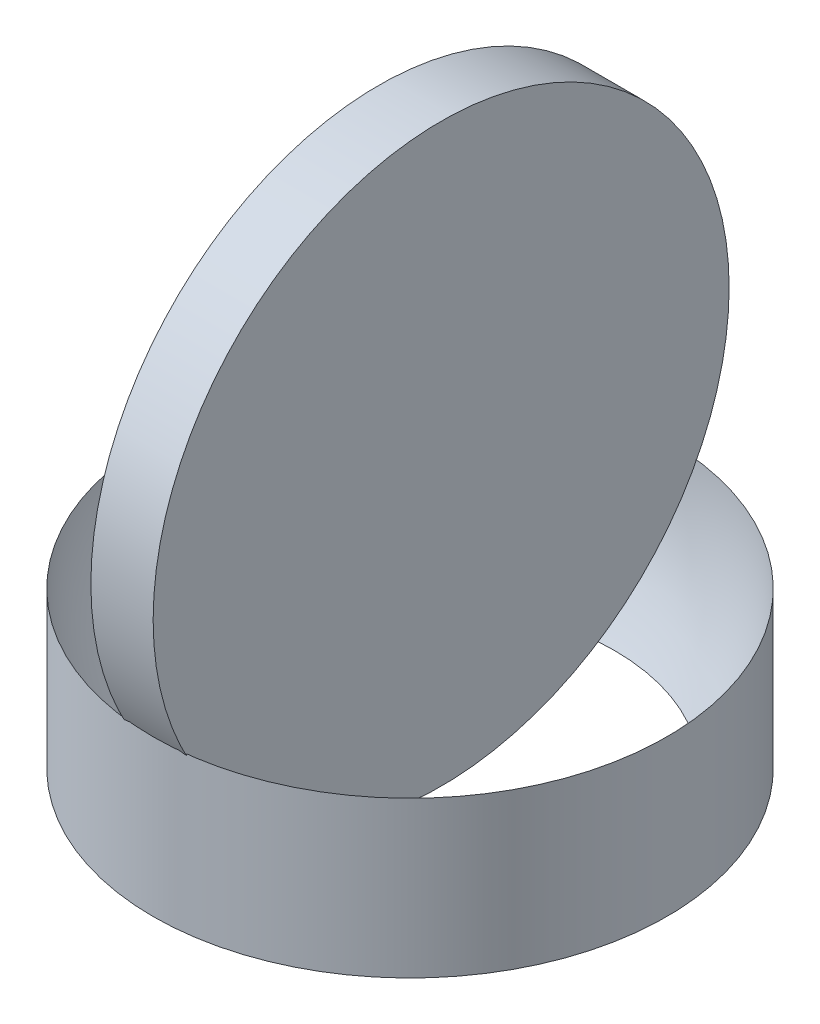
from build123d import *

# Parameters (mm, degrees)
CROQUIS1_R               = 8.25
SALIENTE_EXTRUIR1_DEPTH  = 5
CORTAR_REVOLUCI_N3_ANGLE = 180
CROQUIS3_R               = 9.25
SALIENTE_EXTRUIR3_DEPTH  = 1


with BuildPart() as part:
    # Croquis1 → Saliente-Extruir1 (new body)
    with BuildSketch(Plane(origin=(0, 0, 0), x_dir=(1, 0, 0), z_dir=(0, 1, 0))):
        Circle(CROQUIS1_R)
    extrude(amount=SALIENTE_EXTRUIR1_DEPTH)

    # Croquis4 → Cortar-Revolución3 (revolve, cut)
    with BuildSketch(Plane(origin=(0, 5, 0), x_dir=(1, 0, 0), z_dir=(0, 1, 0))):
        with BuildLine():
            Line((8.25, 0), (-8.25, 0))
            ThreePointArc((-8.25, 0), (0, 8.25), (8.25, 0))
        make_face()
    revolve(axis=Axis((8.25, 5, 0), (-1, 0, 0)), revolution_arc=CORTAR_REVOLUCI_N3_ANGLE, mode=Mode.SUBTRACT)


with BuildPart() as body_2:
    # Croquis3 → Saliente-Extruir3 (new body, symmetric)
    with BuildSketch(Plane(origin=(0, 0, 0), x_dir=(0, 0, -1), z_dir=(1, 0, 0))):
        with Locations((0, 9.25)):
            Circle(CROQUIS3_R)
    extrude(amount=SALIENTE_EXTRUIR3_DEPTH, both=True)


solid = Compound([part.part, body_2.part])
